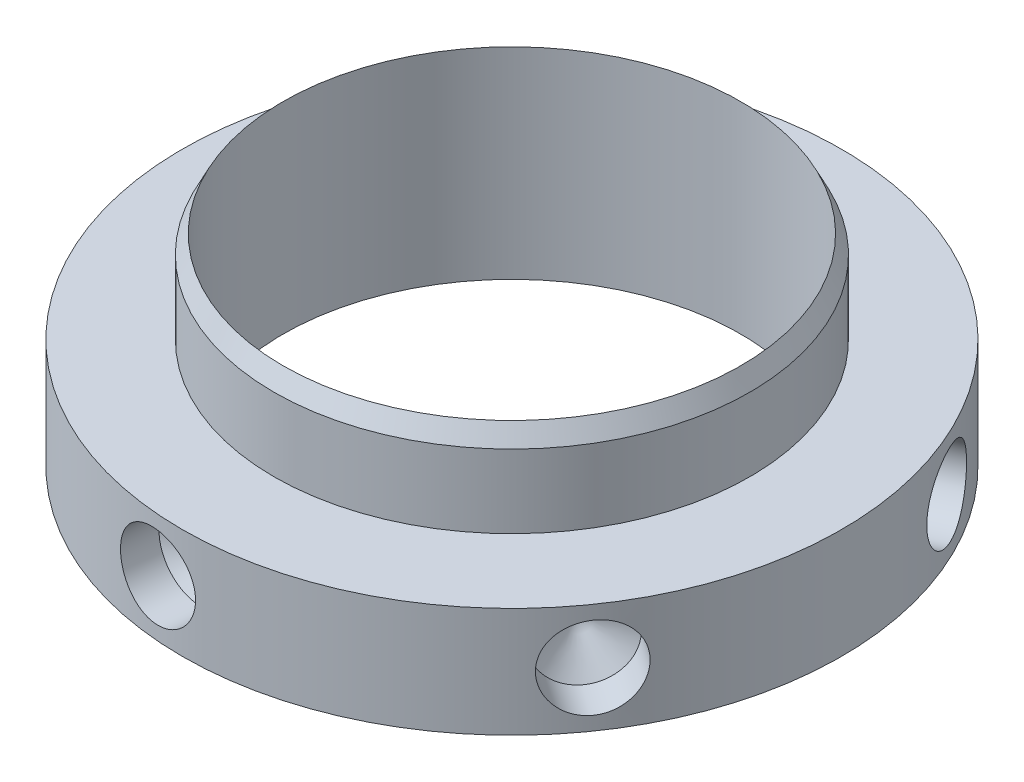
from build123d import *

# Parameters (mm, degrees)
CIRPATTERN1_COUNT = 6


with BuildPart() as part:
    # Sketch1 → Revolve1 (revolve)
    with BuildSketch(Plane(origin=(0, 0, 0), x_dir=(0, 0, -1), z_dir=(1, 0, 0))):
        Polygon((19.84375, 0), (28.575, 0), (28.575, 9.525), (20.6375, 9.525), (20.6375, 15.875), (19.84375, 17.4625), align=None)
    revolve(axis=Axis((0, 73.584156028, 0), (0, -1, 0)))

    # Sketch2 → 9/32 (0.28125) Diameter Hole1 (revolve, cut)
    with BuildSketch(Plane(origin=(23.425888069, 4.7625, 16.363324637), x_dir=(0.572644782, 0, -0.819803607), z_dir=(0, 1, 0))):
        Polygon((0, 0), (0, 5.448199024), (3.571875, 3.302), (3.571875, 0), align=None)
    f_9_32_0_28125_diameter_hole1 = revolve(axis=Axis((28.631640973, 4.7625, 19.999619001), (-0.819803607, 0, -0.572644782)), mode=Mode.SUBTRACT)

    # CirPattern1: 9/32 (0.28125) Diameter Hole1 ×6 about axis
    cirpattern1_axis = Axis((0, 73.584156028, 0), (0, 1, 0))
    for i in range(1, CIRPATTERN1_COUNT):
        add(f_9_32_0_28125_diameter_hole1.rotate(cirpattern1_axis, i * 360 / CIRPATTERN1_COUNT), mode=Mode.SUBTRACT)


solid = part.part
